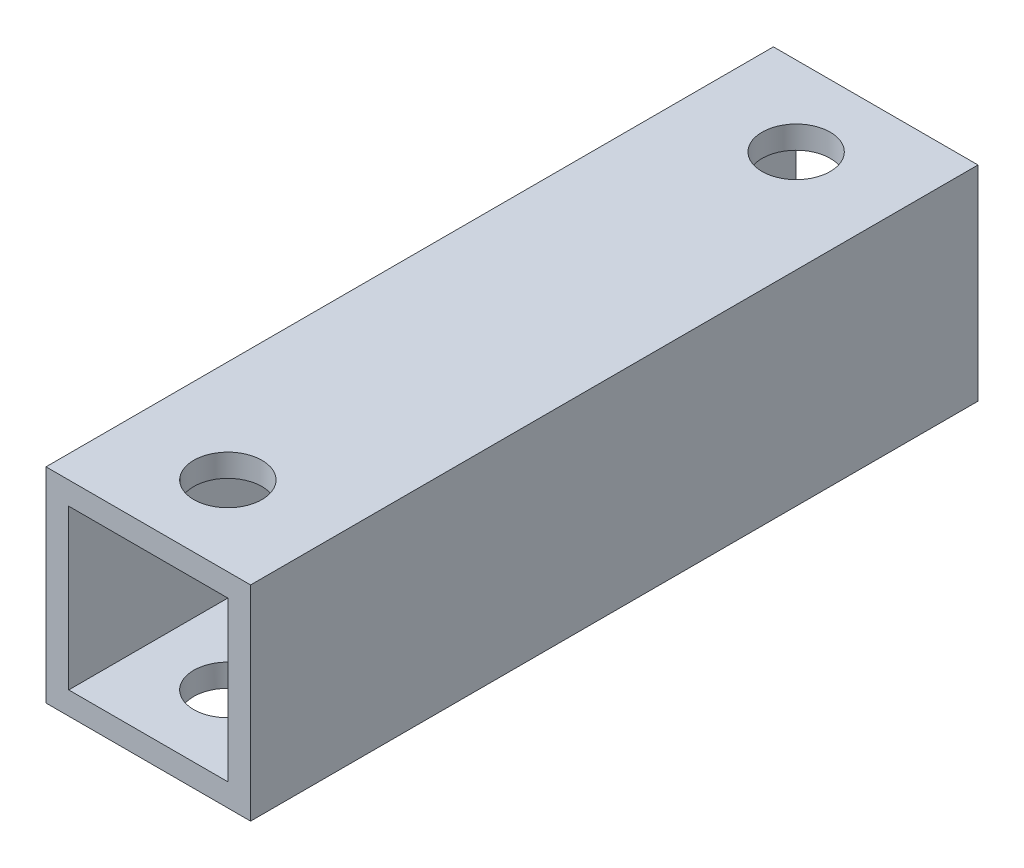
from build123d import *

# Parameters (mm, degrees)
SKETCH_1_W          = 9
SKETCH_1_H          = 9
EXTRUDE_1_DEPTH     = 32
SKETCH_2_W          = 7
SKETCH_2_H          = 7
CUT_EXTRUDE_1_DEPTH = 40
SKETCH_3_R          = 1.5
CUT_EXTRUDE_2_DEPTH = 38


with BuildPart() as part:
    # ｽｹｯﾁ1 → ﾎﾞｽ - 押し出し1 (new body)
    with BuildSketch(Plane.XY):
        Rectangle(SKETCH_1_W, SKETCH_1_H)
    extrude(amount=EXTRUDE_1_DEPTH)

    # ｽｹｯﾁ2 → ｶｯﾄ - 押し出し1 (cut)
    with BuildSketch(Plane.XY.offset(32)):
        Rectangle(SKETCH_2_W, SKETCH_2_H)
    extrude(amount=-CUT_EXTRUDE_1_DEPTH, mode=Mode.SUBTRACT)

    # ｽｹｯﾁ3 → ｶｯﾄ - 押し出し2 (cut)
    with BuildSketch(Plane(origin=(0, 4.5, 0), x_dir=(1, 0, 0), z_dir=(0, 1, 0))):
        with Locations((0, -3.5)):
            Circle(SKETCH_3_R)
        with Locations((0, -28.5)):
            Circle(SKETCH_3_R)
    extrude(amount=-CUT_EXTRUDE_2_DEPTH, mode=Mode.SUBTRACT)


solid = part.part
